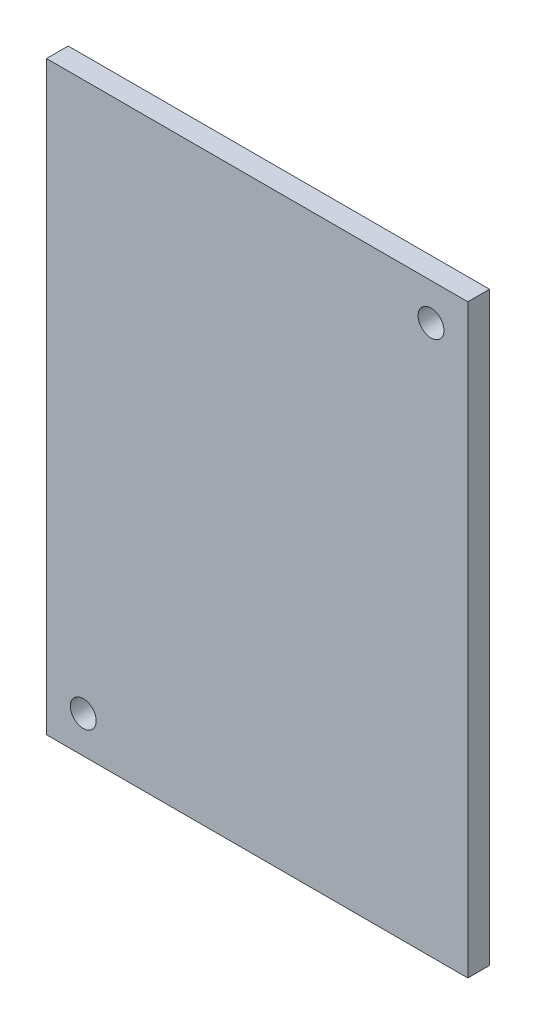
from build123d import *

# Parameters (mm, degrees)
SKETCH2_W                       = 80.86
SKETCH2_H                       = 58.17
BOSS_EXTRUDE1_DEPTH             = 2.9972
F_9_64_0_14063_DIAMETER_HOLE1_D = 3.572002


with BuildPart() as part:
    # Sketch2 → Boss-Extrude1 (new body)
    with BuildSketch(Plane(origin=(0, 0, 0), x_dir=(0, 1, 0), z_dir=(0, 0, 1))):
        Rectangle(SKETCH2_W, SKETCH2_H)
    extrude(amount=BOSS_EXTRUDE1_DEPTH)

    # 9/64 (0.14063) Diameter Hole1 (through all)
    with Locations(Plane.XY.offset(2.9972)):
        with Locations((24.005, 35.35), (-24.005, -35.35)):
            Hole(F_9_64_0_14063_DIAMETER_HOLE1_D / 2)


solid = part.part
